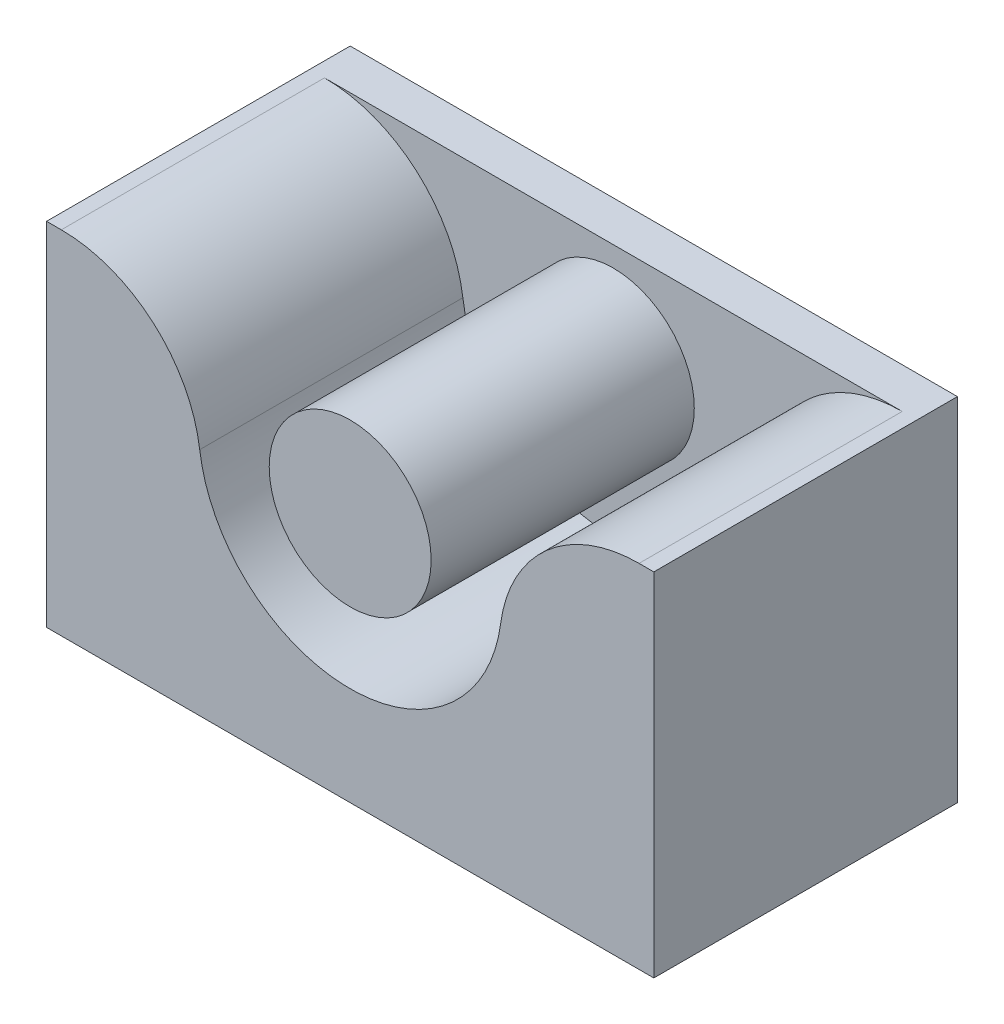
from build123d import *

# Parameters (mm, degrees)
CROQUIS2_W              = 30
CROQUIS2_H              = 17.375045376
SALIENTE_EXTRUIR1_DEPTH = 2
CROQUIS3_R              = 4
SALIENTE_EXTRUIR2_DEPTH = 13


with BuildPart() as part:
    # Croquis2 → Saliente-Extruir1 (new body)
    with BuildSketch(Plane.XY):
        with Locations((0, -3.687522688)):
            Rectangle(CROQUIS2_W, CROQUIS2_H)
    extrude(amount=SALIENTE_EXTRUIR1_DEPTH)

    # Croquis3 → Saliente-Extruir2 (add)
    with BuildSketch(Plane.XY.offset(2)):
        Circle(CROQUIS3_R)
        with BuildLine():
            Line((-15, 5), (-14.271293534, 5))
            ThreePointArc((-14.271293534, 5), (-9.727126272, 3.291298824), (-7.434621256, -0.98813298))
            ThreePointArc((-7.434621256, -0.98813298), (0, -7.5), (7.434621256, -0.98813298))
            ThreePointArc((7.434621256, -0.98813298), (9.727126272, 3.291298824), (14.271293534, 5))
            Line((14.271293534, 5), (15, 5))
            Line((15, 5), (15, -12.375045376))
            Line((15, -12.375045376), (-15, -12.375045376))
            Line((-15, -12.375045376), (-15, 5))
        make_face()
    extrude(amount=SALIENTE_EXTRUIR2_DEPTH)


solid = part.part
